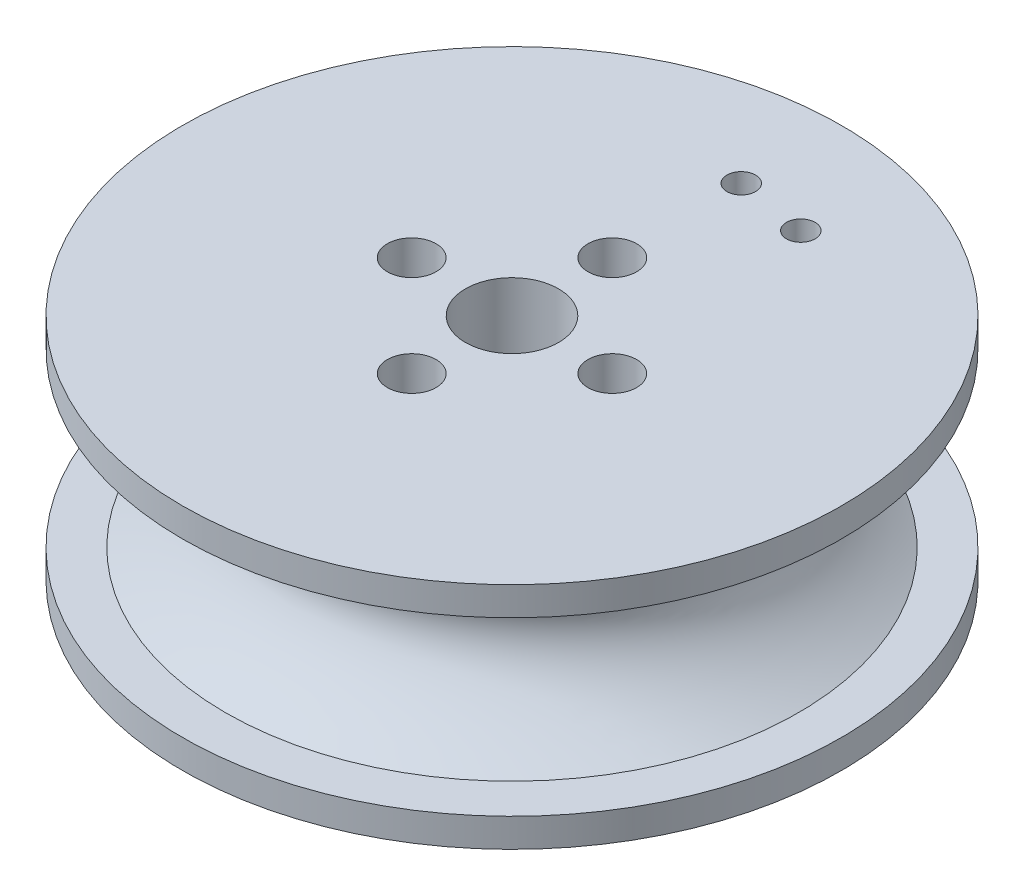
from build123d import *

# Parameters (mm, degrees)
SKETCH_3_R         = 23
EXTRUDE_1_DEPTH    = 2
SKETCH_4_R         = 23
EXTRUDE_2_DEPTH    = 2
HOLE_WIZARD_M3_1_D = 3.4
SKETCH1_R          = 1
SKETCH1_R_2        = 3.25
CUT_EXTRUDE1_DEPTH = 37.249137921


with BuildPart() as part:
    # 草图2 → 旋转1 (revolve)
    with BuildSketch(Plane.XY):
        with BuildLine():
            Line((20, 6), (0, 6))
            Line((0, 6), (0, 0))
            Line((0, 0), (0, -6))
            Line((0, -6), (20, -6))
            add(Edge.make_bspline(
                [(20, 6), (10, 0), (20, -6)],
                knots=[0, 0, 0, 1, 1, 1], degree=2))
        make_face()
    revolve(axis=Axis((0, 6, 0), (0, -1, 0)))

    # 草图3 → 凸台-拉伸1 (add)
    with BuildSketch(Plane(origin=(0, 6, 0), x_dir=(1, 0, 0), z_dir=(0, 1, 0))):
        with Locations(Location((0, 0, 0), (0, 0, 270))):
            Circle(SKETCH_3_R)
    extrude(amount=EXTRUDE_1_DEPTH)

    # 草图4 → 凸台-拉伸2 (add)
    with BuildSketch(Plane.XZ.offset(6)):
        with Locations(Location((0, 0, 0), (0, 0, 90))):
            Circle(SKETCH_4_R)
    extrude(amount=EXTRUDE_2_DEPTH)

    # M3 间隙孔1 (through all)
    with Locations(Plane(origin=(0, 8, 0), x_dir=(1, 0, 0), z_dir=(0, 1, 0))):
        with Locations((0, -7), (0, 7), (-7, 0), (7, 0)):
            Hole(HOLE_WIZARD_M3_1_D / 2)

    # Sketch1 → Cut-Extrude1 (cut, through all)
    with BuildSketch(Plane(origin=(0, 8, 0), x_dir=(1, 0, 0), z_dir=(0, 1, 0))):
        with Locations(Location((0, 16, 0), (0, 0, 270))):
            Circle(SKETCH1_R)
        with Locations(Location((0, 0, 0), (0, 0, 270))):
            Circle(SKETCH1_R_2)
        with Locations(Location((4.938587697, 15.21875, 0), (0, 0, 270))):
            Circle(SKETCH1_R)
    extrude(amount=-CUT_EXTRUDE1_DEPTH, mode=Mode.SUBTRACT)


solid = part.part
